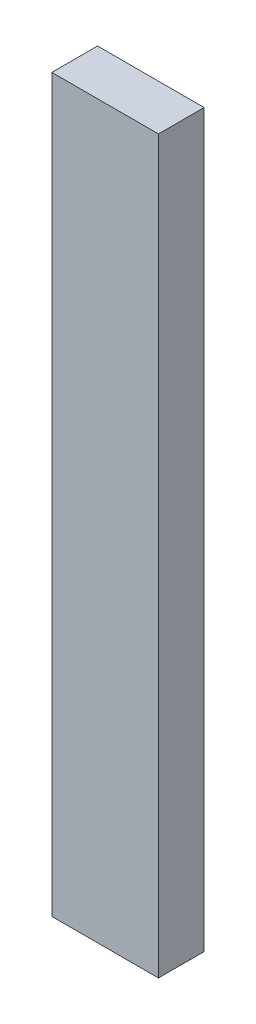
from build123d import *

# Parameters (mm, degrees)
SKETCH1_W           = 88.9
SKETCH1_H           = 38.1
BOSS_EXTRUDE1_DEPTH = 609.6


with BuildPart() as part:
    # Sketch1 → Boss-Extrude1 (new body)
    with BuildSketch(Plane(origin=(0, 0, 0), x_dir=(1, 0, 0), z_dir=(0, 1, 0))):
        Rectangle(SKETCH1_W, SKETCH1_H)
    extrude(amount=BOSS_EXTRUDE1_DEPTH)


solid = part.part
